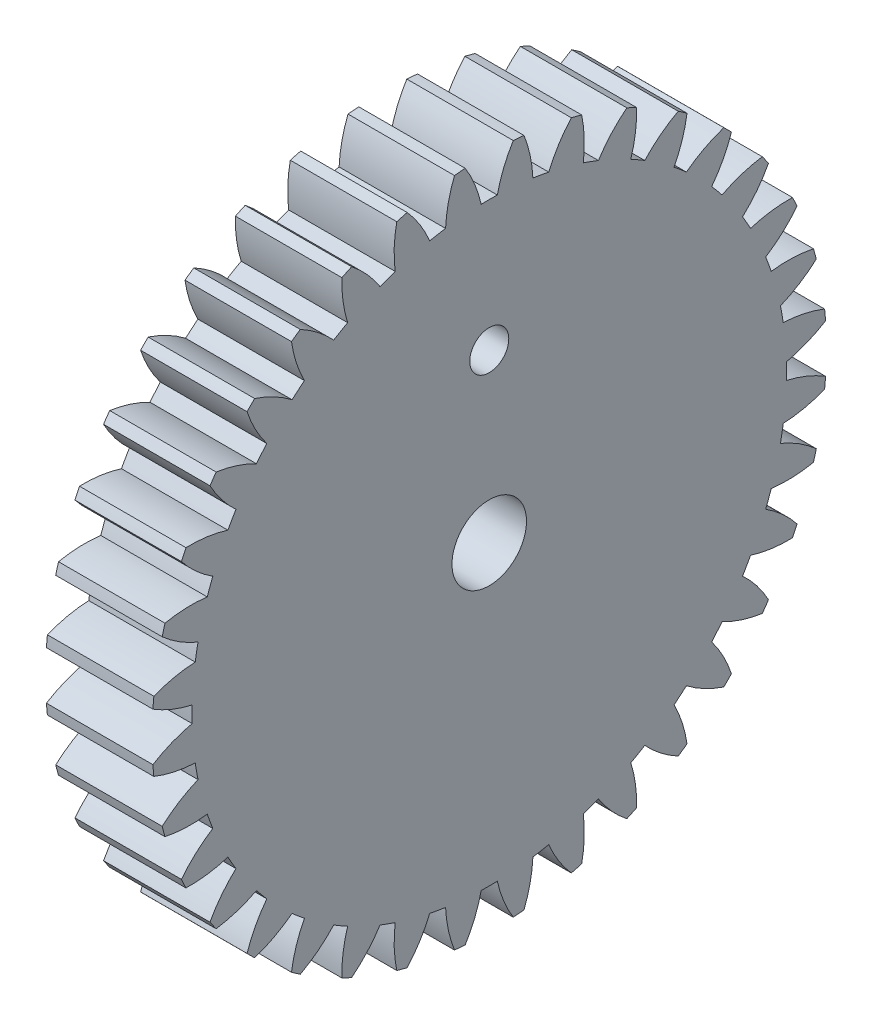
from build123d import *

# Parameters (mm, degrees)
BASPROSKE_W        = 7
BASPROSKE_H        = 19
TOOTHCUT_DEPTH     = 28.766886754
TEETHCUTS_COUNT    = 36
TEETHCUTS_ANGLE    = 350
BORSKE_R           = 0.4
BORE_DEPTH         = 50.0000508
SKETCH1_R          = 2.1
CUT_EXTRUDE1_DEPTH = 10
SKETCH2_R          = 1.1
CUT_EXTRUDE2_DEPTH = 10
SKETCH3_R          = 24.370316762
CUT_EXTRUDE3_DEPTH = 1


with BuildPart() as part:
    # BasProSke → Base-Revolve (revolve)
    with BuildSketch(Plane(origin=(0, 0, 0), x_dir=(1, 0, 0), z_dir=(0, 1, 0)), mode=Mode.PRIVATE) as base_revolve_sk:
        with Locations((3.5, 9.5)):
            Rectangle(BASPROSKE_W, BASPROSKE_H)
    revolve(base_revolve_sk.sketch.rotate(Axis((-10, 0, 0), (1, 0, 0)), 180), axis=Axis((-10, 0, 0), (1, 0, 0)))

    # TooCutSke → ToothCut (cut, through all)
    with BuildSketch(Plane(origin=(0, 0, 0), x_dir=(0, 0, -1), z_dir=(1, 0, 0))):
        with BuildLine():
            ThreePointArc((0.454664826, 16.742827745), (0, 16.749), (-0.454664826, 16.742827745))
            ThreePointArc((-0.454664826, 16.742827745), (-0.817558311, 17.898033097), (-1.368909141, 18.976088452))
            ThreePointArc((-1.368909141, 18.976088452), (0, 19.0254), (1.368909141, 18.976088452))
            ThreePointArc((1.368909141, 18.976088452), (0.817558311, 17.898033097), (0.454664826, 16.742827745))
        make_face()
    toothcut = extrude(amount=TOOTHCUT_DEPTH, mode=Mode.SUBTRACT)

    # TeethCuts: ToothCut ×36 about axis
    teethcuts_axis = Axis((-10, 0, 0), (1, 0, 0))
    for i in range(1, TEETHCUTS_COUNT):
        add(toothcut.rotate(teethcuts_axis, i * TEETHCUTS_ANGLE / (TEETHCUTS_COUNT - 1)), mode=Mode.SUBTRACT)

    # BorSke → Bore (cut, symmetric)
    with BuildSketch(Plane(origin=(0, 0, 0), x_dir=(0, 0, -1), z_dir=(1, 0, 0))):
        with Locations(Location((0, 0, 0), (0, 0, 180))):
            Circle(BORSKE_R)
    extrude(amount=BORE_DEPTH, both=True, mode=Mode.SUBTRACT)

    # Sketch1 → Cut-Extrude1 (cut)
    with BuildSketch(Plane(origin=(7, 0, 0), x_dir=(0, 0, -1), z_dir=(1, 0, 0))):
        Circle(SKETCH1_R)
    extrude(amount=-CUT_EXTRUDE1_DEPTH, mode=Mode.SUBTRACT)

    # Sketch2 → Cut-Extrude2 (cut)
    with BuildSketch(Plane(origin=(7, 0, 0), x_dir=(0, 0, -1), z_dir=(1, 0, 0))):
        with Locations((0, 9.4)):
            Circle(SKETCH2_R)
    extrude(amount=-CUT_EXTRUDE2_DEPTH, mode=Mode.SUBTRACT)

    # Sketch3 → Cut-Extrude3 (cut)
    with BuildSketch(Plane.ZY):
        Circle(SKETCH3_R)
    extrude(amount=-CUT_EXTRUDE3_DEPTH, mode=Mode.SUBTRACT)


solid = part.part
